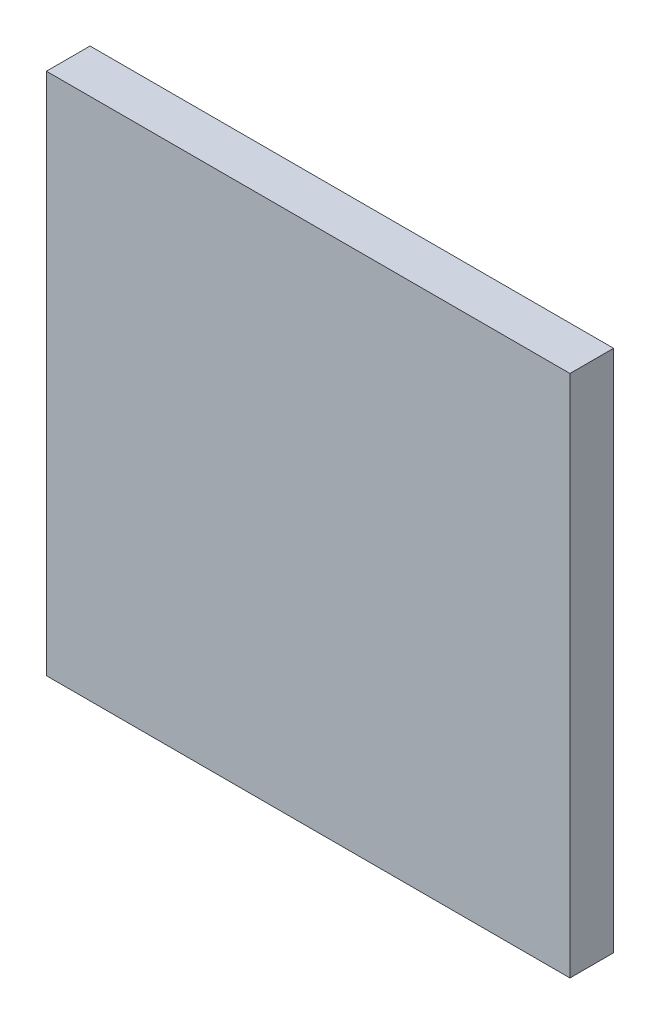
from build123d import *

# Parameters (mm, degrees)
SKETCH1_W           = 304.8
SKETCH1_H           = 304.8
BOSS_EXTRUDE1_DEPTH = 25.4


with BuildPart() as part:
    # Sketch1 → Boss-Extrude1 (new body)
    with BuildSketch(Plane.XY):
        Rectangle(SKETCH1_W, SKETCH1_H)
    extrude(amount=BOSS_EXTRUDE1_DEPTH)


solid = part.part
